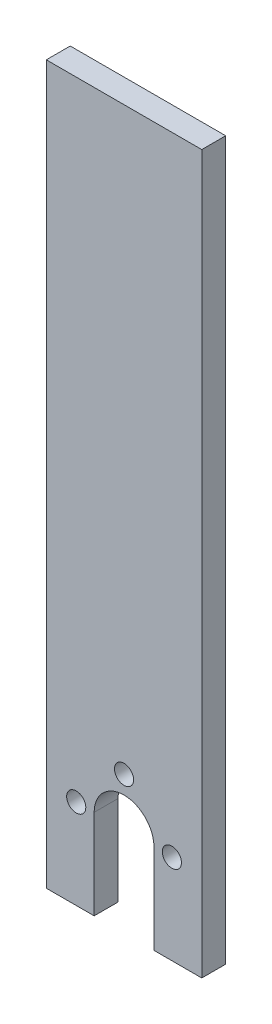
from build123d import *

# Parameters (mm, degrees)
SKETCH_1_R      = 1.6
EXTRUDE_1_DEPTH = 4


with BuildPart() as part:
    # 草图1 → 凸台-拉伸1 (new body)
    with BuildSketch(Plane.XY):
        with BuildLine():
            Line((-8, -15), (-13, -15))
            Line((-13, -15), (-13, -12))
            Line((-13, -12), (-13, 105))
            Line((-13, 105), (-11, 105))
            Line((-11, 105), (11, 105))
            Line((11, 105), (13, 105))
            Line((13, 105), (13, -12))
            Line((13, -12), (13, -15))
            Line((13, -15), (8, -15))
            Line((8, -15), (5, -15))
            Line((5, -15), (5, 0))
            ThreePointArc((5, 0), (0, 5), (-5, 0))
            Line((-5, 0), (-5, -15))
            Line((-5, -15), (-8, -15))
        make_face()
        with Locations((8, 0)):
            Circle(SKETCH_1_R, mode=Mode.SUBTRACT)
        with Locations((-8, 0)):
            Circle(SKETCH_1_R, mode=Mode.SUBTRACT)
        with Locations((0, 8)):
            Circle(SKETCH_1_R, mode=Mode.SUBTRACT)
    extrude(amount=EXTRUDE_1_DEPTH)


solid = part.part
